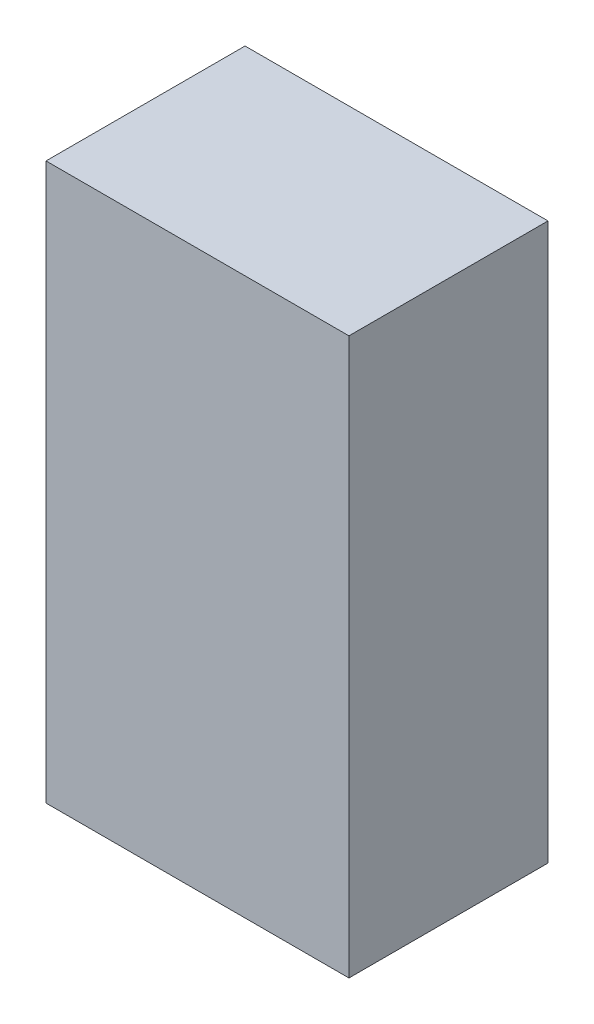
from build123d import *

# Parameters (mm, degrees)
ESBO_O1_W                = 20.7
ESBO_O1_H                = 38
RESSALTO_EXTRUS_O1_DEPTH = 13.6


with BuildPart() as part:
    # Esboço1 → Ressalto-extrusão1 (new body)
    with BuildSketch(Plane.XY):
        with Locations((10.35, -19)):
            Rectangle(ESBO_O1_W, ESBO_O1_H)
    extrude(amount=RESSALTO_EXTRUS_O1_DEPTH)


solid = part.part
